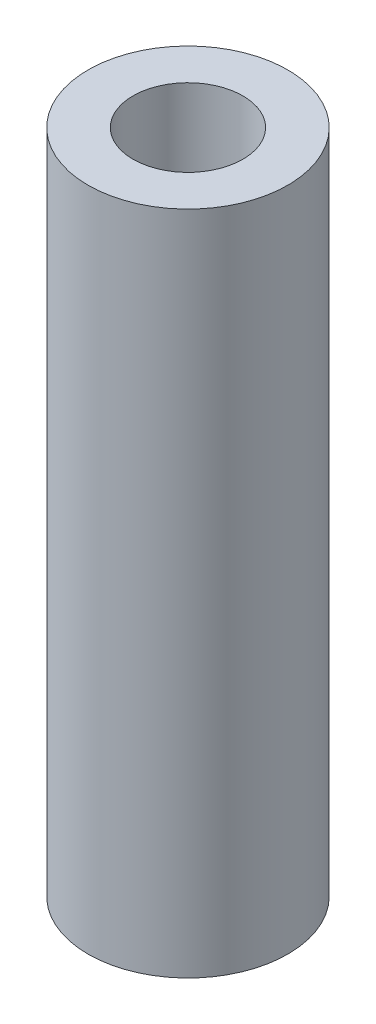
from build123d import *

# Parameters (mm, degrees)
SKETCH1_R           = 3
SKETCH1_R_2         = 1.65
BOSS_EXTRUDE1_DEPTH = 20


with BuildPart() as part:
    # Sketch1 → Boss-Extrude1 (new body)
    with BuildSketch(Plane(origin=(0, 0, 0), x_dir=(1, 0, 0), z_dir=(0, 1, 0))):
        Circle(SKETCH1_R)
        Circle(SKETCH1_R_2, mode=Mode.SUBTRACT)
    extrude(amount=BOSS_EXTRUDE1_DEPTH)


solid = part.part
